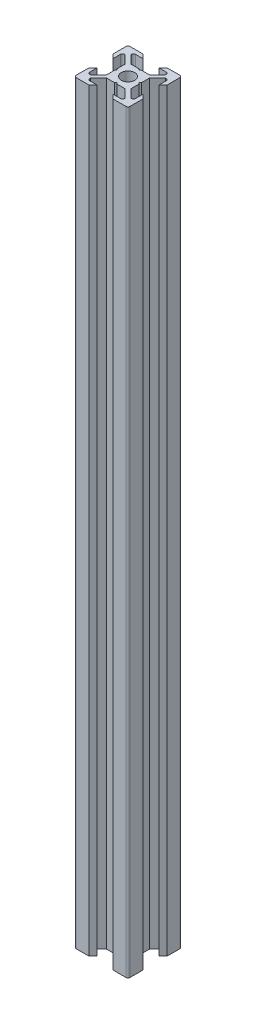
from build123d import *

# Parameters (mm, degrees)
ESQUISSE1_R      = 2.5
EXTRUSION1_DEPTH = 280
CONG_1_R         = 0.75


with BuildPart() as part:
    # Esquisse1 → Extrusion1 (new body)
    with BuildSketch(Plane(origin=(0, 0, 0), x_dir=(1, 0, 0), z_dir=(0, 1, 0))):
        Polygon((0, 4), (-0.5, 4.5), (-3.439339828, 4.5), (-6.439339828, 7.5), (-6.439339828, 8.5), (-3, 8.5), (-4.5, 10), (-10, 10), (-10, 4.5), (-8.5, 3), (-8.5, 6.439339828), (-7.5, 6.439339828), (-4.5, 3.439339828), (-4.5, 0.5), (-4, 0), (-4.5, -0.5), (-4.5, -3.439339828), (-7.5, -6.439339828), (-8.5, -6.439339828), (-8.5, -3), (-10, -4.5), (-10, -10), (-4.5, -10), (-3, -8.5), (-6.439339828, -8.5), (-6.439339828, -7.5), (-3.439339828, -4.5), (-0.5, -4.5), (0, -4), (0.5, -4.5), (3.439339828, -4.5), (6.439339828, -7.5), (6.439339828, -8.5), (3, -8.5), (4.5, -10), (10, -10), (10, -4.5), (8.5, -3), (8.5, -6.439339828), (7.5, -6.439339828), (4.5, -3.439339828), (4.5, -0.5), (4, 0), (4.5, 0.5), (4.5, 3.439339828), (7.5, 6.439339828), (8.5, 6.439339828), (8.5, 3), (10, 4.5), (10, 10), (4.5, 10), (3, 8.5), (6.439339828, 8.5), (6.439339828, 7.5), (3.439339828, 4.5), (0.5, 4.5), align=None)
        Circle(ESQUISSE1_R, mode=Mode.SUBTRACT)
    extrude(amount=EXTRUSION1_DEPTH)

    # Congé1
    cong_1_edges = [part.edges().sort_by_distance(p)[0] for p in [
        (6.439339828, 140, -8.5),
        (10, 140, -10),
        (8.5, 140, -6.439339828),
        (8.5, 140, 6.439339828),
        (10, 140, 10),
        (6.439339828, 140, 8.5),
        (-6.439339828, 140, 8.5),
        (-10, 140, 10),
        (-8.5, 140, 6.439339828),
        (-8.5, 140, -6.439339828),
        (-10, 140, -10),
        (-6.439339828, 140, -8.5),
    ]]
    fillet(cong_1_edges, radius=CONG_1_R)


solid = part.part
